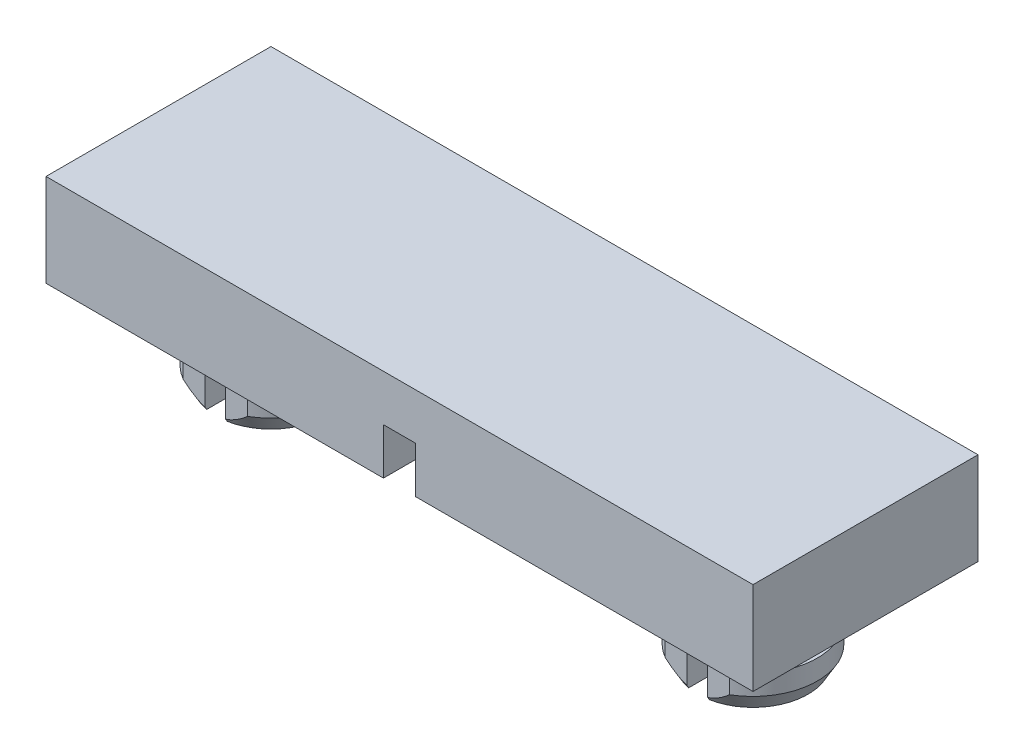
from build123d import *

# Parameters (mm, degrees)
SKETCH1_W             = 34.925
SKETCH1_H             = 11.1125
BOSS_EXTRUDE1_DEPTH   = 4.572
SKETCH2_W             = 1.5875
SKETCH2_H             = 11.1125
CUT_EXTRUDE1_DEPTH    = 2.286
BOSS_EXTRUDE2_DEPTH   = 2.54
BOSS_EXTRUDE3_DEPTH   = 1.778
CHAMFER1_SIZE         = 0.79375
CHAMFER1_SIZE2        = 0.458271776
CHAMFER1_PART_2_SIZE  = 0.79375
CHAMFER1_PART_2_SIZE2 = 0.458271776
CHAMFER1_PART_3_SIZE  = 0.79375
CHAMFER1_PART_3_SIZE2 = 0.458271776
CHAMFER1_PART_4_SIZE  = 0.79375
CHAMFER1_PART_4_SIZE2 = 0.458271776


with BuildPart() as part:
    # Sketch1 → Boss-Extrude1 (new body)
    with BuildSketch(Plane(origin=(0, 0, 0), x_dir=(1, 0, 0), z_dir=(0, 1, 0))):
        with Locations((17.4625, 5.55625)):
            Rectangle(SKETCH1_W, SKETCH1_H)
    extrude(amount=BOSS_EXTRUDE1_DEPTH)

    # Sketch2 → Cut-Extrude1 (cut)
    with BuildSketch(Plane.XZ):
        with Locations((17.4625, -5.55625)):
            Rectangle(SKETCH2_W, SKETCH2_H)
    extrude(amount=-CUT_EXTRUDE1_DEPTH, mode=Mode.SUBTRACT)

    # Sketch3 → Boss-Extrude2 (add)
    with BuildSketch(Plane.XZ):
        with BuildLine():
            Line((5.04825, -2.808819928), (5.04825, -8.303680072))
            ThreePointArc((5.04825, -8.303680072), (2.76225, -5.55625), (5.04825, -2.808819928))
        make_face()
        with BuildLine():
            Line((6.06425, -2.808819928), (6.06425, -8.303680072))
            ThreePointArc((6.06425, -8.303680072), (8.35025, -5.55625), (6.06425, -2.808819928))
        make_face()
        with BuildLine():
            Line((28.86075, -2.808819928), (28.86075, -8.303680072))
            ThreePointArc((28.86075, -8.303680072), (26.57475, -5.55625), (28.86075, -2.808819928))
        make_face()
        with BuildLine():
            Line((29.87675, -2.808819928), (29.87675, -8.303680072))
            ThreePointArc((29.87675, -8.303680072), (32.16275, -5.55625), (29.87675, -2.808819928))
        make_face()
    extrude(amount=BOSS_EXTRUDE2_DEPTH)

    # Sketch4 → Boss-Extrude3 (add)
    with BuildSketch(Plane.XZ.offset(2.54)):
        with BuildLine():
            Line((5.04825, -2.808819928), (5.04825, -8.303680072))
            Line((5.04825, -8.303680072), (3.964944561, -8.303680072))
            ThreePointArc((3.964944561, -8.303680072), (2.38125, -5.55625), (3.964944561, -2.808819928))
            Line((3.964944561, -2.808819928), (5.04825, -2.808819928))
        make_face()
        with BuildLine():
            Line((6.06425, -2.808819928), (6.06425, -8.303680072))
            Line((6.06425, -8.303680072), (7.147555439, -8.303680072))
            ThreePointArc((7.147555439, -8.303680072), (8.73125, -5.55625), (7.147555439, -2.808819928))
            Line((7.147555439, -2.808819928), (6.06425, -2.808819928))
        make_face()
        with BuildLine():
            Line((28.86075, -2.808819928), (27.777444561, -2.808819928))
            ThreePointArc((27.777444561, -2.808819928), (26.19375, -5.55625), (27.777444561, -8.303680072))
            Line((27.777444561, -8.303680072), (28.86075, -8.303680072))
            Line((28.86075, -8.303680072), (28.86075, -2.808819928))
        make_face()
        with BuildLine():
            Line((29.87675, -2.808819928), (30.960055439, -2.808819928))
            ThreePointArc((30.960055439, -2.808819928), (32.54375, -5.55625), (30.960055439, -8.303680072))
            Line((30.960055439, -8.303680072), (29.87675, -8.303680072))
            Line((29.87675, -8.303680072), (29.87675, -2.808819928))
        make_face()
    extrude(amount=BOSS_EXTRUDE3_DEPTH)

    # Chamfer1
    chamfer1_edges = [part.edges().sort_by_distance(p)[0] for p in [
        (32.54375, -4.318, -5.55625),
    ]]
    chamfer1_side = [part.faces().sort_by_distance(p)[0] for p in [
        (32.54375, -3.429, -5.55625),
    ]]
    chamfer(chamfer1_edges, length=CHAMFER1_SIZE, length2=CHAMFER1_SIZE2, reference=chamfer1_side[0])

    # Chamfer1 part 2
    chamfer1_part_2_edges = [part.edges().sort_by_distance(p)[0] for p in [
        (26.19375, -4.318, -5.55625),
    ]]
    chamfer1_part_2_side = [part.faces().sort_by_distance(p)[0] for p in [
        (26.19375, -3.429, -5.55625),
    ]]
    chamfer(chamfer1_part_2_edges, length=CHAMFER1_PART_2_SIZE, length2=CHAMFER1_PART_2_SIZE2, reference=chamfer1_part_2_side[0])

    # Chamfer1 part 3
    chamfer1_part_3_edges = [part.edges().sort_by_distance(p)[0] for p in [
        (2.38125, -4.318, -5.55625),
    ]]
    chamfer1_part_3_side = [part.faces().sort_by_distance(p)[0] for p in [
        (2.38125, -3.429, -5.55625),
    ]]
    chamfer(chamfer1_part_3_edges, length=CHAMFER1_PART_3_SIZE, length2=CHAMFER1_PART_3_SIZE2, reference=chamfer1_part_3_side[0])

    # Chamfer1 part 4
    chamfer1_part_4_edges = [part.edges().sort_by_distance(p)[0] for p in [
        (8.73125, -4.318, -5.55625),
    ]]
    chamfer1_part_4_side = [part.faces().sort_by_distance(p)[0] for p in [
        (8.73125, -3.429, -5.55625),
    ]]
    chamfer(chamfer1_part_4_edges, length=CHAMFER1_PART_4_SIZE, length2=CHAMFER1_PART_4_SIZE2, reference=chamfer1_part_4_side[0])


solid = part.part
